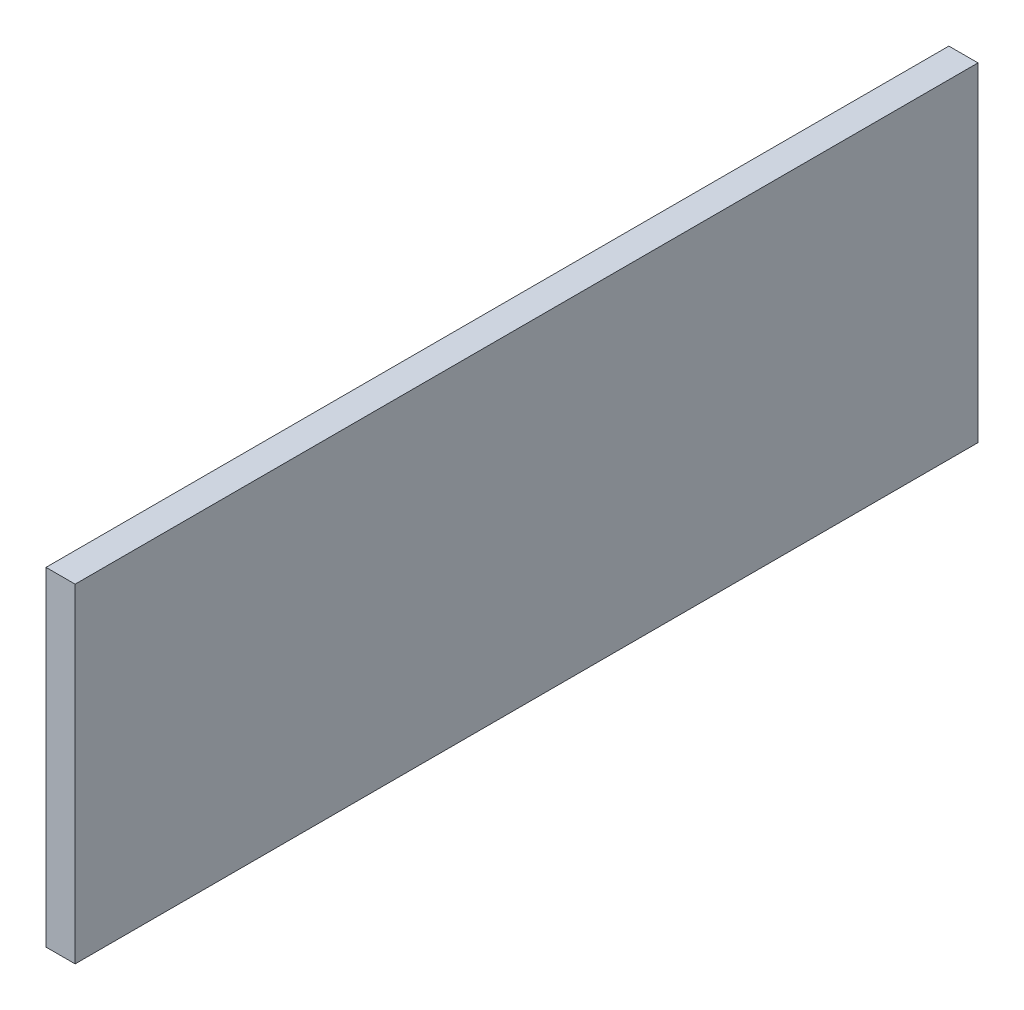
from build123d import *

# Parameters (mm, degrees)
SKETCH1_W           = 93
SKETCH1_H           = 33.876964868
BOSS_EXTRUDE1_DEPTH = 3


with BuildPart() as part:
    # Sketch1 → Boss-Extrude1 (new body)
    with BuildSketch(Plane(origin=(0, 0, 0), x_dir=(0, 0, -1), z_dir=(1, 0, 0))):
        with Locations((-5.461616981, -39.775181141)):
            Rectangle(SKETCH1_W, SKETCH1_H)
    extrude(amount=BOSS_EXTRUDE1_DEPTH)


solid = part.part
